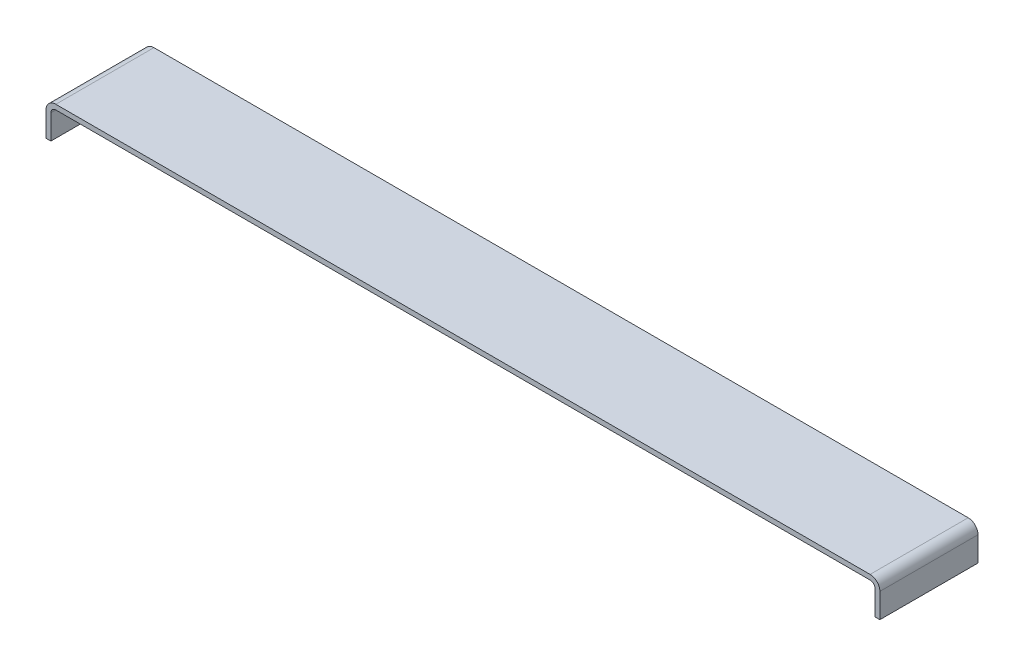
from build123d import *

# Parameters (mm, degrees)
RESSALTO_EXTRUS_O1_DEPTH = 20


with BuildPart() as part:
    # Esboço1 → Ressalto-extrusão1 (new body)
    with BuildSketch(Plane.XY):
        with BuildLine():
            Line((0, 0), (0, 5))
            ThreePointArc((0, 5), (0.585786438, 6.414213562), (2, 7))
            Line((2, 7), (168, 7))
            ThreePointArc((168, 7), (169.414213562, 6.414213562), (170, 5))
            Line((170, 5), (170, 0))
            Line((170, 0), (169, 0))
            Line((169, 0), (169, 5))
            ThreePointArc((169, 5), (168.707106781, 5.707106781), (168, 6))
            Line((168, 6), (2, 6))
            ThreePointArc((2, 6), (1.292893219, 5.707106781), (1, 5))
            Line((1, 5), (1, 0))
            Line((1, 0), (0, 0))
        make_face()
    extrude(amount=RESSALTO_EXTRUS_O1_DEPTH)


solid = part.part
